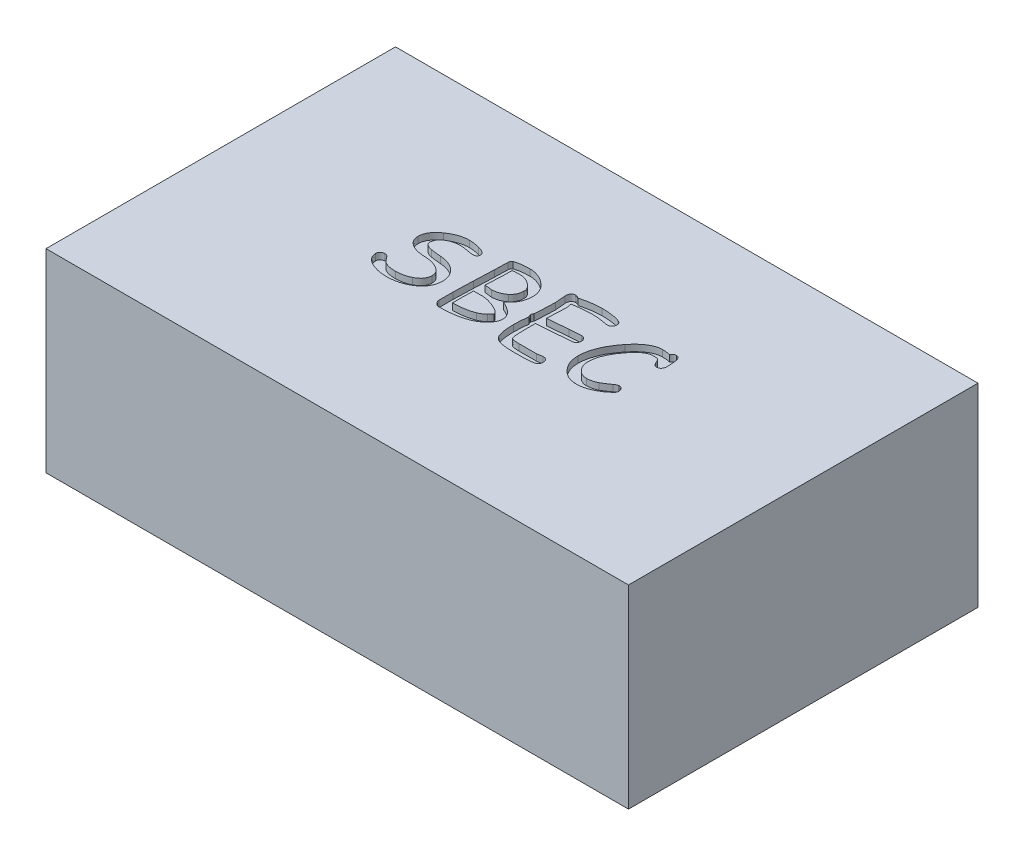
from build123d import *

# Parameters (mm, degrees)
SKICA1_W                 = 45
SKICA1_H                 = 27
P_IDAT_VYSUNUT_M1_DEPTH  = 15
ODEBRAT_VYSUNUT_M1_DEPTH = 0.5


with BuildPart() as part:
    # Skica1 → Přidat vysunutím1 (new body)
    with BuildSketch(Plane(origin=(0, 0, 0), x_dir=(1, 0, 0), z_dir=(0, 1, 0))):
        Rectangle(SKICA1_W, SKICA1_H)
    extrude(amount=P_IDAT_VYSUNUT_M1_DEPTH)

    # Skica2 → Odebrat vysunutím1 (cut)
    with BuildSketch(Plane(origin=(0, 15, 0), x_dir=(1, 0, 0), z_dir=(0, 1, 0))):
        with BuildLine():
            add(Edge.make_bspline(
                [(-9.448428748, -1.088679229), (-9.447731937, -1.06391265), (-9.446385447, -1.016054698), (-9.425496132, -0.947757461), (-9.390459162, -0.886735555), (-9.34168447, -0.834456243), (-9.283141779, -0.791103366), (-9.216734416, -0.760278758), (-9.143711397, -0.742089885), (-9.093271746, -0.739524158), (-9.067080901, -0.738191901)],
                knots=[0, 0, 0, 0, 7.405e-05, 0.000143092, 0.000211718, 0.000283486, 0.000356011, 0.000428987, 0.000501696, 0.000580229, 0.000580229, 0.000580229, 0.000580229], degree=3))
            add(Edge.make_bspline(
                [(-9.067080901, -0.738191901), (-9.036859517, -0.740334049), (-8.975703771, -0.744668883), (-8.889705252, -0.787561448), (-8.809282366, -0.851942649), (-8.766061049, -0.909328917), (-8.743045448, -0.939887439)],
                knots=[0, 0, 0, 0, 9.0095e-05, 0.000182315, 0.000282666, 0.000396972, 0.000396972, 0.000396972, 0.000396972], degree=3))
            add(Edge.make_bspline(
                [(-8.743045448, -0.939887439), (-8.712673736, -0.982146428), (-8.655801588, -1.061277942), (-8.569312316, -1.166111756), (-8.488016575, -1.250199945), (-8.430924359, -1.292825252), (-8.404681896, -1.312417995)],
                knots=[0, 0, 0, 0, 0.000156072, 0.00029225, 0.000407593, 0.00050571, 0.00050571, 0.00050571, 0.00050571], degree=3))
            add(Edge.make_bspline(
                [(-8.404681896, -1.312417995), (-8.377084825, -1.32884305), (-8.320479073, -1.362533315), (-8.226768677, -1.402320085), (-8.125508436, -1.438330834), (-8.014479987, -1.464946021), (-7.894924712, -1.487010104), (-7.766575626, -1.503764673), (-7.628869477, -1.511987479), (-7.53435067, -1.513388914), (-7.485479282, -1.514113532)],
                knots=[0, 0, 0, 0, 9.6242e-05, 0.000197407, 0.000304765, 0.000418373, 0.00053943, 0.000669438, 0.000806391, 0.000953015, 0.000953015, 0.000953015, 0.000953015], degree=3))
            add(Edge.make_bspline(
                [(-7.485479282, -1.514113532), (-7.437704911, -1.513071583), (-7.343136342, -1.511009062), (-7.202425049, -1.500442723), (-7.064657962, -1.479763414), (-6.928583334, -1.454057783), (-6.795399511, -1.418601042), (-6.665154838, -1.374928981), (-6.536630817, -1.326444796), (-6.454303946, -1.286253996), (-6.413076232, -1.266127215)],
                knots=[0, 0, 0, 0, 0.000143349, 0.000283757, 0.000422948, 0.00056107, 0.000699017, 0.000835991, 0.000973125, 0.001110688, 0.001110688, 0.001110688, 0.001110688], degree=3))
            add(Edge.make_bspline(
                [(-6.413076232, -1.266127215), (-6.3628633, -1.239249348), (-6.266607593, -1.187725804), (-6.136831815, -1.0963028), (-6.027361844, -0.997032605), (-5.93569017, -0.890727888), (-5.86731173, -0.774430137), (-5.816422368, -0.651537075), (-5.78598834, -0.520330313), (-5.782302907, -0.430110412), (-5.780435584, -0.384398089)],
                knots=[0, 0, 0, 0, 0.00017075, 0.000327319, 0.000474782, 0.000613221, 0.000746669, 0.000877659, 0.001011075, 0.001148103, 0.001148103, 0.001148103, 0.001148103], degree=3))
            add(Edge.make_bspline(
                [(-5.780435584, -0.384398089), (-5.782245433, -0.346432126), (-5.785797743, -0.271913825), (-5.810551573, -0.162970838), (-5.852951718, -0.060694045), (-5.912611703, 0.035246025), (-5.98828602, 0.125086371), (-6.080964155, 0.207954146), (-6.189990823, 0.284444514), (-6.270770486, 0.328061023), (-6.312779544, 0.350743569)],
                knots=[0, 0, 0, 0, 0.000113865, 0.000223489, 0.000333197, 0.000444538, 0.000561101, 0.000684396, 0.000816494, 0.000959627, 0.000959627, 0.000959627, 0.000959627], degree=3))
            add(Edge.make_bspline(
                [(-6.312779544, 0.350743569), (-6.351065057, 0.369768629), (-6.428538359, 0.408267112), (-6.551936437, 0.454624333), (-6.680817919, 0.496923204), (-6.816570452, 0.532257504), (-6.95948287, 0.559650705), (-7.108936132, 0.579807699), (-7.264723881, 0.596312509), (-7.370811523, 0.600104467), (-7.424860404, 0.60203637)],
                knots=[0, 0, 0, 0, 0.000128178, 0.000259377, 0.000394961, 0.000535039, 0.000679864, 0.000831213, 0.000987382, 0.001149583, 0.001149583, 0.001149583, 0.001149583], degree=3))
            add(Edge.make_bspline(
                [(-7.424860404, 0.60203637), (-7.47302536, 0.604472442), (-7.567715331, 0.609261642), (-7.706776265, 0.62493208), (-7.840345507, 0.646847291), (-7.968496831, 0.675293077), (-8.091110021, 0.711191191), (-8.209171811, 0.750972848), (-8.321030567, 0.799735208), (-8.391701509, 0.837780764), (-8.426725124, 0.856635655)],
                knots=[0, 0, 0, 0, 0.000144652, 0.000284379, 0.00041955, 0.000550573, 0.000677895, 0.000802678, 0.000924101, 0.0010434, 0.0010434, 0.0010434, 0.0010434], degree=3))
            add(Edge.make_bspline(
                [(-8.426725124, 0.856635655), (-8.468519121, 0.88176397), (-8.549985552, 0.930745027), (-8.658143547, 1.018152382), (-8.750336823, 1.113675149), (-8.824007562, 1.218340548), (-8.88442705, 1.329412656), (-8.924144889, 1.45008352), (-8.951224352, 1.578078998), (-8.953496426, 1.666575217), (-8.954660438, 1.711912908)],
                knots=[0, 0, 0, 0, 0.000146156, 0.000284893, 0.00041586, 0.000543087, 0.000667826, 0.000793651, 0.00092291, 0.001058695, 0.001058695, 0.001058695, 0.001058695], degree=3))
            add(Edge.make_bspline(
                [(-8.954660438, 1.711912908), (-8.95222202, 1.76610134), (-8.947327352, 1.874874504), (-8.910779597, 2.035353684), (-8.851207605, 2.192076105), (-8.767968108, 2.344976511), (-8.658821219, 2.492665214), (-8.530005256, 2.639103996), (-8.374752018, 2.779502376), (-8.259559664, 2.866066421), (-8.199679874, 2.911064519)],
                knots=[0, 0, 0, 0, 0.000162471, 0.00032613, 0.000491119, 0.000664229, 0.000846552, 0.001040961, 0.001248478, 0.00147313, 0.00147313, 0.00147313, 0.00147313], degree=3))
            add(Edge.make_bspline(
                [(-8.199679874, 2.911064519), (-8.140027214, 2.952054094), (-8.022585488, 3.032752698), (-7.838760173, 3.135769617), (-7.654464146, 3.224496731), (-7.468713394, 3.297981691), (-7.281024769, 3.354423543), (-7.091808138, 3.393748016), (-6.901308164, 3.419472655), (-6.77356509, 3.422201998), (-6.709557651, 3.423569573)],
                knots=[0, 0, 0, 0, 0.000217036, 0.000427292, 0.000631383, 0.000830322, 0.001025939, 0.00121854, 0.001409656, 0.001601588, 0.001601588, 0.001601588, 0.001601588], degree=3))
            add(Edge.make_bspline(
                [(-6.709557651, 3.423569573), (-6.647048131, 3.421882626), (-6.518001139, 3.418400029), (-6.318680187, 3.395426138), (-6.108306773, 3.356495459), (-5.965420114, 3.320757022), (-5.891753886, 3.302331819)],
                knots=[0, 0, 0, 0, 0.000187526, 0.000387136, 0.000601154, 0.000828918, 0.000828918, 0.000828918, 0.000828918], degree=3))
            add(Edge.make_bspline(
                [(-5.891753886, 3.302331819), (-5.844184578, 3.289319306), (-5.754912068, 3.264898945), (-5.631453531, 3.221739386), (-5.526426947, 3.176584472), (-5.440546236, 3.126978544), (-5.373010907, 3.075339389), (-5.3231877, 3.021093826), (-5.293265364, 2.961501189), (-5.288827795, 2.920167203), (-5.286667274, 2.900042905)],
                knots=[0, 0, 0, 0, 0.000147912, 0.000277583, 0.000392065, 0.000490361, 0.000574364, 0.000646217, 0.000709808, 0.000770146, 0.000770146, 0.000770146, 0.000770146], degree=3))
            add(Edge.make_bspline(
                [(-5.286667274, 2.900042905), (-5.287621106, 2.87458768), (-5.289410988, 2.82682051), (-5.305321713, 2.760062768), (-5.32992715, 2.70241576), (-5.367848182, 2.655435129), (-5.416665044, 2.619769749), (-5.475259887, 2.594040138), (-5.544328657, 2.58035604), (-5.593378128, 2.578238303), (-5.619520019, 2.577109612)],
                knots=[0, 0, 0, 0, 7.6249e-05, 0.000143082, 0.000204744, 0.000262751, 0.000321828, 0.000384496, 0.000453238, 0.000531685, 0.000531685, 0.000531685, 0.000531685], degree=3))
            add(Edge.make_bspline(
                [(-5.619520019, 2.577109612), (-5.648949904, 2.578116003), (-5.717252878, 2.580451707), (-5.833167778, 2.597271822), (-5.977139437, 2.618070669), (-6.13966856, 2.65025042), (-6.305600807, 2.681961459), (-6.459311834, 2.703826273), (-6.592467426, 2.717651037), (-6.674261833, 2.718018022), (-6.711761974, 2.718186273)],
                knots=[0, 0, 0, 0, 8.8283e-05, 0.000204894, 0.00035095, 0.000524749, 0.0007018, 0.000857669, 0.000990483, 0.001102925, 0.001102925, 0.001102925, 0.001102925], degree=3))
            add(Edge.make_bspline(
                [(-6.711761974, 2.718186273), (-6.759191167, 2.716560894), (-6.852411571, 2.713366268), (-6.988969811, 2.698792112), (-7.120163306, 2.676988569), (-7.245839292, 2.646182164), (-7.3664461, 2.606586538), (-7.481124133, 2.557669209), (-7.590912969, 2.501867718), (-7.659590164, 2.45791773), (-7.693787788, 2.436032952)],
                knots=[0, 0, 0, 0, 0.000142333, 0.00027975, 0.000411659, 0.00054104, 0.000667559, 0.00079202, 0.000914761, 0.001036499, 0.001036499, 0.001036499, 0.001036499], degree=3))
            add(Edge.make_bspline(
                [(-7.693787788, 2.436032952), (-7.726651023, 2.412836811), (-7.790348969, 2.36787634), (-7.874629051, 2.290928549), (-7.946231226, 2.210747381), (-8.0064118, 2.127184408), (-8.051346092, 2.038849667), (-8.083749023, 1.946953327), (-8.104600331, 1.851350534), (-8.106989977, 1.785865161), (-8.108200477, 1.75269288)],
                knots=[0, 0, 0, 0, 0.00012058, 0.000233716, 0.000341447, 0.000442666, 0.000541744, 0.000637607, 0.000734446, 0.000833861, 0.000833861, 0.000833861, 0.000833861], degree=3))
            add(Edge.make_bspline(
                [(-8.108200477, 1.75269288), (-8.106427551, 1.728235593), (-8.10289115, 1.679451401), (-8.076452339, 1.609354477), (-8.031539569, 1.546088513), (-7.969287937, 1.489803218), (-7.890881089, 1.439262472), (-7.796168873, 1.393968248), (-7.683722637, 1.356144486), (-7.60247103, 1.335837726), (-7.559324096, 1.325054254)],
                knots=[0, 0, 0, 0, 7.3275e-05, 0.00014616, 0.000221373, 0.000304043, 0.000396362, 0.000500374, 0.000618187, 0.00075159, 0.00075159, 0.00075159, 0.00075159], degree=3))
            add(Edge.make_bspline(
                [(-7.559324096, 1.325054254), (-7.540258674, 1.320810147), (-7.498666132, 1.311551333), (-7.42937957, 1.301091247), (-7.348534814, 1.290192329), (-7.255568089, 1.27920128), (-7.150850403, 1.268229217), (-7.03436526, 1.257418042), (-6.905837074, 1.245950849), (-6.816114358, 1.240000828), (-6.769074367, 1.236881341)],
                knots=[0, 0, 0, 0, 5.8581e-05, 0.000127798, 0.000210099, 0.000303334, 0.000408618, 0.000525966, 0.000654291, 0.000795716, 0.000795716, 0.000795716, 0.000795716], degree=3))
            add(Edge.make_bspline(
                [(-6.769074367, 1.236881341), (-6.700236492, 1.230598618), (-6.565561116, 1.218307011), (-6.370416962, 1.18235803), (-6.186308847, 1.135404833), (-6.013822498, 1.075046837), (-5.853271374, 1.000578121), (-5.703639802, 0.9148017), (-5.565805513, 0.815332282), (-5.48323426, 0.73918883), (-5.442072032, 0.701230897)],
                knots=[0, 0, 0, 0, 0.00020728, 0.000405525, 0.000594522, 0.000776832, 0.000952882, 0.001124724, 0.001293595, 0.001461461, 0.001461461, 0.001461461, 0.001461461], degree=3))
            add(Edge.make_bspline(
                [(-5.442072032, 0.701230897), (-5.407144584, 0.6651647), (-5.338096864, 0.593865799), (-5.248970248, 0.476501223), (-5.173284989, 0.353180694), (-5.111230907, 0.224024807), (-5.063814939, 0.088597736), (-5.029647847, -0.052398365), (-5.007894511, -0.199292473), (-5.00565118, -0.299455035), (-5.004513953, -0.350231086)],
                knots=[0, 0, 0, 0, 0.000150513, 0.000297547, 0.000441019, 0.000583981, 0.000726553, 0.000870637, 0.001018712, 0.001170954, 0.001170954, 0.001170954, 0.001170954], degree=3))
            add(Edge.make_bspline(
                [(-5.004513953, -0.350231086), (-5.007047559, -0.42205079), (-5.012035604, -0.563446112), (-5.051667927, -0.769531825), (-5.115582444, -0.964881051), (-5.207268688, -1.148142986), (-5.32417289, -1.320320117), (-5.466925781, -1.481138372), (-5.635374727, -1.630946091), (-5.762485937, -1.717570065), (-5.827828525, -1.762099849)],
                knots=[0, 0, 0, 0, 0.000215328, 0.000423928, 0.000627124, 0.0008302, 0.001036542, 0.001249716, 0.00147378, 0.001710809, 0.001710809, 0.001710809, 0.001710809], degree=3))
            add(Edge.make_bspline(
                [(-5.827828525, -1.762099849), (-5.887937776, -1.798638166), (-6.008299677, -1.871801969), (-6.198347438, -1.965429741), (-6.396121817, -2.043630373), (-6.600759952, -2.107228757), (-6.811829628, -2.158967763), (-7.030543701, -2.192874145), (-7.256078472, -2.216506705), (-7.408998898, -2.218490418), (-7.486581443, -2.219496833)],
                knots=[0, 0, 0, 0, 0.000210954, 0.000422411, 0.000634651, 0.000848336, 0.001064868, 0.001285928, 0.001511847, 0.001744497, 0.001744497, 0.001744497, 0.001744497], degree=3))
            add(Edge.make_bspline(
                [(-7.486581443, -2.219496833), (-7.54318345, -2.218607945), (-7.655046688, -2.216851225), (-7.821263321, -2.204098567), (-7.983666189, -2.185128459), (-8.142424653, -2.155672569), (-8.297392686, -2.119702796), (-8.4491109, -2.075547625), (-8.597010259, -2.022725737), (-8.692926751, -1.981221858), (-8.740841125, -1.960488902)],
                knots=[0, 0, 0, 0, 0.00016979, 0.000335558, 0.00049988, 0.000660073, 0.000819677, 0.000976978, 0.001133857, 0.001290449, 0.001290449, 0.001290449, 0.001290449], degree=3))
            add(Edge.make_bspline(
                [(-8.740841125, -1.960488902), (-8.795817431, -1.934044849), (-8.901441847, -1.883238642), (-9.044308429, -1.79213315), (-9.167227749, -1.694912842), (-9.266178921, -1.587304217), (-9.346639866, -1.474497083), (-9.403101922, -1.352235658), (-9.440167981, -1.223058877), (-9.445658165, -1.133748901), (-9.448428748, -1.088679229)],
                knots=[0, 0, 0, 0, 0.000182869, 0.000351341, 0.000507292, 0.000651574, 0.000788549, 0.000921184, 0.00105381, 0.001188923, 0.001188923, 0.001188923, 0.001188923], degree=3))
        make_face()
        with BuildLine():
            add(Edge.make_bspline(
                [(-1.32109053, -1.889950572), (-1.39206123, -1.91655142), (-1.537291749, -1.970985926), (-1.766066426, -2.037505259), (-2.009048896, -2.093380985), (-2.26654589, -2.139498567), (-2.538289515, -2.17581598), (-2.824804089, -2.200548767), (-3.125152643, -2.216268624), (-3.330310577, -2.218405855), (-3.435036109, -2.219496833)],
                knots=[0, 0, 0, 0, 0.000227313, 0.00046516, 0.000714065, 0.000975008, 0.001249661, 0.001536244, 0.001837529, 0.002151694, 0.002151694, 0.002151694, 0.002151694], degree=3))
            add(Edge.make_bspline(
                [(-3.435036109, -2.219496833), (-3.461368248, -2.217440334), (-3.51435698, -2.213301995), (-3.59225831, -2.183183452), (-3.667276919, -2.135090127), (-3.736806094, -2.069708327), (-3.796584361, -1.995408654), (-3.842383481, -1.917057611), (-3.870595486, -1.836364159), (-3.874151786, -1.78140973), (-3.875900672, -1.754384719)],
                knots=[0, 0, 0, 0, 7.888e-05, 0.000158731, 0.000247406, 0.000344902, 0.000443704, 0.000532563, 0.000616211, 0.00069715, 0.00069715, 0.00069715, 0.00069715], degree=3))
            Line((-3.875900672, -1.754384719), (-3.875900672, -0.664347087))
            add(Edge.make_bspline(
                [(-3.875900672, -0.664347087), (-3.875599657, -0.617320833), (-3.874967031, -0.518488592), (-3.872589169, -0.363083472), (-3.869524512, -0.193333746), (-3.864006982, -0.009261048), (-3.85556199, 0.188706915), (-3.848575025, 0.401113382), (-3.838460716, 0.627790639), (-3.830438054, 0.783897759), (-3.826303409, 0.864350785)],
                knots=[0, 0, 0, 0, 0.000141081, 0.000296501, 0.000466266, 0.00065041, 0.000848949, 0.001060704, 0.001287966, 0.001529644, 0.001529644, 0.001529644, 0.001529644], degree=3))
            add(Edge.make_bspline(
                [(-3.826303409, 0.864350785), (-3.821784918, 0.950681376), (-3.813095039, 1.116710762), (-3.802302307, 1.3566445), (-3.792434522, 1.578180236), (-3.783195542, 1.78131543), (-3.776991687, 1.966141599), (-3.770964472, 2.132176434), (-3.767905877, 2.279887218), (-3.766390748, 2.372107254), (-3.765684531, 2.415091886)],
                knots=[0, 0, 0, 0, 0.000259345, 0.000498768, 0.000720525, 0.000924615, 0.001108795, 0.001275312, 0.001423039, 0.001552011, 0.001552011, 0.001552011, 0.001552011], degree=3))
            add(Edge.make_bspline(
                [(-3.765684531, 2.415091886), (-3.765752931, 2.445585263), (-3.765897976, 2.510247894), (-3.764669527, 2.612386292), (-3.762433619, 2.725176395), (-3.759107447, 2.848253545), (-3.754644141, 2.981982719), (-3.749133818, 3.126000143), (-3.742492625, 3.280670485), (-3.737438453, 3.387200209), (-3.734824012, 3.442306317)],
                knots=[0, 0, 0, 0, 9.1479e-05, 0.000193986, 0.000306428, 0.000429915, 0.000563349, 0.000707837, 0.000862282, 0.001027786, 0.001027786, 0.001027786, 0.001027786], degree=3))
            add(Edge.make_bspline(
                [(-3.734824012, 3.442306317), (-3.729935791, 3.471230695), (-3.720908783, 3.524644935), (-3.694129681, 3.595482803), (-3.659840444, 3.652837722), (-3.626939518, 3.677519438), (-3.611381934, 3.689190473)],
                knots=[0, 0, 0, 0, 8.7759e-05, 0.000162063, 0.000226565, 0.000284426, 0.000284426, 0.000284426, 0.000284426], degree=3))
            add(Edge.make_bspline(
                [(-3.611381934, 3.689190473), (-3.523959986, 3.714002367), (-3.345360167, 3.764692154), (-3.063401237, 3.810541826), (-2.765263628, 3.841692109), (-2.560376755, 3.845067215), (-2.455214618, 3.846799554)],
                knots=[0, 0, 0, 0, 0.000272415, 0.000556533, 0.000855601, 0.001170975, 0.001170975, 0.001170975, 0.001170975], degree=3))
            add(Edge.make_bspline(
                [(-2.455214618, 3.846799554), (-2.400404871, 3.845624823), (-2.291115422, 3.843282435), (-2.128127304, 3.821308581), (-1.96689756, 3.786338363), (-1.807629905, 3.735829728), (-1.649537484, 3.673341514), (-1.493682391, 3.595194022), (-1.338836952, 3.504184245), (-1.240100321, 3.433189401), (-1.189933322, 3.3971177)],
                knots=[0, 0, 0, 0, 0.000164355, 0.000327721, 0.000492456, 0.000658736, 0.000828405, 0.001001907, 0.001181288, 0.00136657, 0.00136657, 0.00136657, 0.00136657], degree=3))
            add(Edge.make_bspline(
                [(-1.189933322, 3.3971177), (-1.13429892, 3.353719498), (-1.02619464, 3.269391616), (-0.882631223, 3.128312793), (-0.761904058, 2.979126539), (-0.662441722, 2.822088545), (-0.584442947, 2.657592726), (-0.530727951, 2.484596501), (-0.496062096, 2.304791382), (-0.492079299, 2.181962146), (-0.490060828, 2.119712628)],
                knots=[0, 0, 0, 0, 0.000211552, 0.00041107, 0.000602307, 0.000786081, 0.000967523, 0.001146691, 0.001328277, 0.001514868, 0.001514868, 0.001514868, 0.001514868], degree=3))
            add(Edge.make_bspline(
                [(-0.490060828, 2.119712628), (-0.492269777, 2.041310681), (-0.496588322, 1.888033086), (-0.53387348, 1.664904544), (-0.594467292, 1.454567188), (-0.680115289, 1.256859374), (-0.789446359, 1.071524747), (-0.925019637, 0.900692065), (-1.083231965, 0.741335351), (-1.20418132, 0.649143415), (-1.265982459, 0.60203637)],
                knots=[0, 0, 0, 0, 0.000235073, 0.000459574, 0.000676523, 0.000890277, 0.00110425, 0.001320107, 0.001543, 0.00177589, 0.00177589, 0.00177589, 0.00177589], degree=3))
            add(Edge.make_bspline(
                [(-1.265982459, 0.60203637), (-1.220268806, 0.582175559), (-1.1306964, 0.543259817), (-1.002465297, 0.48058109), (-0.882674872, 0.416745641), (-0.772572891, 0.35051052), (-0.670976632, 0.283349311), (-0.577831308, 0.215092697), (-0.493761196, 0.144521039), (-0.418792603, 0.071784794), (-0.352462571, -0.002195045), (-0.294214706, -0.077034513), (-0.246873774, -0.155170678), (-0.206907866, -0.234219279), (-0.17582703, -0.315082235), (-0.153565096, -0.39739978), (-0.139857832, -0.481662118), (-0.13820286, -0.538649722), (-0.137369178, -0.567356883)],
                knots=[0, 0, 0, 0, 0.000149509, 0.00029295, 0.000428063, 0.000556596, 0.000678259, 0.000793328, 0.000902836, 0.00100728, 0.001106408, 0.001200757, 0.001291302, 0.001380024, 0.001466197, 0.001550684, 0.001635486, 0.001721567, 0.001721567, 0.001721567, 0.001721567], degree=3))
            add(Edge.make_bspline(
                [(-0.137369178, -0.567356883), (-0.138984861, -0.604925527), (-0.142243129, -0.680688363), (-0.16480992, -0.793506902), (-0.203168286, -0.905107462), (-0.256443514, -1.015705936), (-0.32557444, -1.124910877), (-0.409179572, -1.233468581), (-0.506882827, -1.341506121), (-0.580940051, -1.408917992), (-0.619013713, -1.443575202)],
                knots=[0, 0, 0, 0, 0.000112685, 0.000227246, 0.000343659, 0.000465914, 0.000594659, 0.000730673, 0.000876579, 0.00103096, 0.00103096, 0.00103096, 0.00103096], degree=3))
            add(Edge.make_bspline(
                [(-0.619013713, -1.443575202), (-0.674388327, -1.491306267), (-0.7833771, -1.585250946), (-0.95846959, -1.70543489), (-1.135754982, -1.810415022), (-1.259839702, -1.863665176), (-1.32109053, -1.889950572)],
                knots=[0, 0, 0, 0, 0.000219156, 0.000431344, 0.000636269, 0.000836031, 0.000836031, 0.000836031, 0.000836031], degree=3))
        make_face()
        with BuildLine():
            add(Edge.make_bspline(
                [(-2.445295165, 3.070877923), (-2.509231039, 3.070974194), (-2.627212047, 3.071151844), (-2.788480454, 3.064914713), (-2.919511257, 3.058799155), (-2.996039788, 3.049560449), (-3.029440711, 3.045528211)],
                knots=[0, 0, 0, 0, 0.000191779, 0.000353891, 0.000484174, 0.000585075, 0.000585075, 0.000585075, 0.000585075], degree=3))
            Line((-3.029440711, 3.045528211), (-3.03605368, 2.416194047))
            Line((-3.03605368, 2.416194047), (-3.099979041, 1.025266351))
            add(Edge.make_bspline(
                [(-3.099979041, 1.025266351), (-3.057745098, 1.019271669), (-2.978469536, 1.008019304), (-2.867065048, 0.993966042), (-2.771540485, 0.981856787), (-2.691472473, 0.971809401), (-2.627173711, 0.963978827), (-2.578658351, 0.95900816), (-2.546037882, 0.954296541), (-2.529432519, 0.954615132), (-2.523548625, 0.954728021)],
                knots=[0, 0, 0, 0, 0.000127969, 0.000240206, 0.000336858, 0.000416831, 0.000482314, 0.000531122, 0.000563255, 0.000580889, 0.000580889, 0.000580889, 0.000580889], degree=3))
            add(Edge.make_bspline(
                [(-2.523548625, 0.954728021), (-2.476832498, 0.959383833), (-2.385275031, 0.968508614), (-2.251425476, 0.990220946), (-2.123893001, 1.021104973), (-2.003365292, 1.060986973), (-1.888531225, 1.106820817), (-1.781483773, 1.162881622), (-1.679580064, 1.224636598), (-1.617491521, 1.273350526), (-1.586711429, 1.297500218)],
                knots=[0, 0, 0, 0, 0.000140822, 0.000275993, 0.000406445, 0.00053401, 0.000656608, 0.000776885, 0.000896168, 0.001013438, 0.001013438, 0.001013438, 0.001013438], degree=3))
            add(Edge.make_bspline(
                [(-1.586711429, 1.297500218), (-1.555544252, 1.324730866), (-1.494155696, 1.378365823), (-1.414945851, 1.469604271), (-1.347027342, 1.565837725), (-1.291547627, 1.66793161), (-1.248149979, 1.775877779), (-1.217155375, 1.889743387), (-1.199673341, 2.009692304), (-1.196870592, 2.091369069), (-1.195444129, 2.132938565)],
                knots=[0, 0, 0, 0, 0.000124036, 0.000244308, 0.000361418, 0.000476824, 0.000592051, 0.000709694, 0.000830026, 0.000954746, 0.000954746, 0.000954746, 0.000954746], degree=3))
            add(Edge.make_bspline(
                [(-1.195444129, 2.132938565), (-1.19679783, 2.161697209), (-1.199516028, 2.21944384), (-1.219152214, 2.304749575), (-1.249978458, 2.388493357), (-1.295337082, 2.469351083), (-1.351972626, 2.549364874), (-1.421789238, 2.627362108), (-1.504198149, 2.703428709), (-1.596517987, 2.777281604), (-1.695993298, 2.845435714), (-1.79895173, 2.905162966), (-1.902797992, 2.956014112), (-2.007857728, 2.998621809), (-2.115384995, 3.030456973), (-2.224130904, 3.053285595), (-2.334273006, 3.068708529), (-2.408137145, 3.070151848), (-2.445295165, 3.070877923)],
                knots=[0, 0, 0, 0, 8.6223e-05, 0.000173133, 0.000261368, 0.000353112, 0.000450359, 0.000554977, 0.000666492, 0.000786465, 0.00090936, 0.001027887, 0.00114323, 0.001256002, 0.001367587, 0.001479129, 0.001589179, 0.001700585, 0.001700585, 0.001700585, 0.001700585], degree=3))
        make_face(mode=Mode.SUBTRACT)
        with BuildLine():
            Line((-2.022065185, 0.124800481), (-2.418843292, 0.189828004))
            add(Edge.make_bspline(
                [(-2.418843292, 0.189828004), (-2.439054205, 0.189594788), (-2.488327724, 0.189026215), (-2.566532859, 0.184318784), (-2.645838543, 0.179536453), (-2.696215484, 0.179023437), (-2.717529033, 0.17880639)],
                knots=[0, 0, 0, 0, 6.0629e-05, 0.000147811, 0.000234993, 0.000298928, 0.000298928, 0.000298928, 0.000298928], degree=3))
            add(Edge.make_bspline(
                [(-2.717529033, 0.17880639), (-2.787332589, 0.17880639), (-2.930980959, 0.17880639), (-3.074629329, 0.17880639), (-3.148474143, 0.17880639)],
                knots=[0, 0, 0, 0, 0.000209411, 0.000430945, 0.000430945, 0.000430945, 0.000430945], degree=3))
            add(Edge.make_bspline(
                [(-3.148474143, 0.17880639), (-3.152018921, 0.102031251), (-3.158903404, -0.047077408), (-3.165009133, -0.264609506), (-3.170121338, -0.469607826), (-3.170388079, -0.602255594), (-3.170517371, -0.66655141)],
                knots=[0, 0, 0, 0, 0.000230565, 0.000447792, 0.000652841, 0.000845723, 0.000845723, 0.000845723, 0.000845723], degree=3))
            Line((-3.170517371, -0.66655141), (-3.170517371, -1.443575202))
            add(Edge.make_bspline(
                [(-3.170517371, -1.443575202), (-3.090763131, -1.440060261), (-2.934771717, -1.433185383), (-2.706504091, -1.414242544), (-2.489202213, -1.389184998), (-2.283307373, -1.357289671), (-2.088817865, -1.319556484), (-1.906535015, -1.272047533), (-1.734202962, -1.222164226), (-1.625387156, -1.179835664), (-1.572383331, -1.159217559)],
                knots=[0, 0, 0, 0, 0.000239476, 0.000468392, 0.000686992, 0.00089556, 0.001093339, 0.001280995, 0.001460566, 0.001631102, 0.001631102, 0.001631102, 0.001631102], degree=3))
            add(Edge.make_bspline(
                [(-1.572383331, -1.159217559), (-1.528538854, -1.14073661), (-1.439582979, -1.103240688), (-1.313435708, -1.027542327), (-1.188286297, -0.940625757), (-1.110671722, -0.872365071), (-1.07089989, -0.837386428)],
                knots=[0, 0, 0, 0, 0.000142571, 0.000289262, 0.000440323, 0.000599084, 0.000599084, 0.000599084, 0.000599084], degree=3))
            add(Edge.make_bspline(
                [(-1.07089989, -0.837386428), (-1.036665415, -0.806866839), (-0.975740577, -0.75255314), (-0.90482032, -0.671333064), (-0.855132322, -0.603783149), (-0.846402522, -0.557889442), (-0.842752479, -0.538700686)],
                knots=[0, 0, 0, 0, 0.000137245, 0.000244245, 0.000324974, 0.000382982, 0.000382982, 0.000382982, 0.000382982], degree=3))
            add(Edge.make_bspline(
                [(-0.842752479, -0.538700686), (-0.844465696, -0.523045498), (-0.848087044, -0.489954017), (-0.872562509, -0.441295587), (-0.911177648, -0.392513636), (-0.965418791, -0.343472312), (-1.032887724, -0.291374878), (-1.116014764, -0.239220622), (-1.213633169, -0.185030382), (-1.284540562, -0.15039478), (-1.322192691, -0.132003127)],
                knots=[0, 0, 0, 0, 4.6929e-05, 9.9198e-05, 0.000160484, 0.000233001, 0.000317875, 0.000416017, 0.000527029, 0.000652719, 0.000652719, 0.000652719, 0.000652719], degree=3))
            add(Edge.make_bspline(
                [(-1.322192691, -0.132003127), (-1.381483093, -0.10466613), (-1.498274501, -0.05081717), (-1.67423936, 0.019645208), (-1.848147886, 0.079081369), (-1.964553219, 0.109681823), (-2.022065185, 0.124800481)],
                knots=[0, 0, 0, 0, 0.000195841, 0.000385771, 0.000568404, 0.000746754, 0.000746754, 0.000746754, 0.000746754], degree=3))
        make_face(mode=Mode.SUBTRACT)
        with BuildLine():
            add(Edge.make_bspline(
                [(4.290013196, 3.070877923), (4.271596915, 3.071553816), (4.232327221, 3.072995046), (4.193697601, 3.080250821), (4.173184087, 3.08410386)],
                knots=[0, 0, 0, 0, 5.5207e-05, 0.00011772, 0.00011772, 0.00011772, 0.00011772], degree=3))
            add(Edge.make_bspline(
                [(4.173184087, 3.08410386), (4.068293382, 3.103980174), (3.861116969, 3.143239167), (3.551178678, 3.181623586), (3.247085315, 3.207753315), (3.046094235, 3.210562357), (2.94647844, 3.211954583)],
                knots=[0, 0, 0, 0, 0.000320191, 0.000632429, 0.000936492, 0.001235277, 0.001235277, 0.001235277, 0.001235277], degree=3))
            add(Edge.make_bspline(
                [(2.94647844, 3.211954583), (2.893567986, 3.211518885), (2.785870823, 3.210632039), (2.62050334, 3.203556945), (2.44852086, 3.192645139), (2.269195622, 3.177117141), (2.083378029, 3.156734484), (1.889824282, 3.134603266), (1.689860064, 3.103797337), (1.554067168, 3.081975156), (1.485012414, 3.070877923)],
                knots=[0, 0, 0, 0, 0.000158727, 0.000323082, 0.000496472, 0.000675687, 0.000863006, 0.001057268, 0.001260057, 0.001469885, 0.001469885, 0.001469885, 0.001469885], degree=3))
            add(Edge.make_bspline(
                [(1.485012414, 3.070877923), (1.495716177, 3.030563215), (1.515851813, 2.954724249), (1.538022464, 2.846226326), (1.552412789, 2.750533005), (1.55456064, 2.690672382), (1.555550744, 2.663078202)],
                knots=[0, 0, 0, 0, 0.000125104, 0.000235342, 0.000332138, 0.000414917, 0.000414917, 0.000414917, 0.000414917], degree=3))
            add(Edge.make_bspline(
                [(1.555550744, 2.663078202), (1.55531882, 2.615683587), (1.554833347, 2.516475389), (1.551282572, 2.36106114), (1.545811683, 2.193155465), (1.537920311, 2.01240043), (1.528044849, 1.819146789), (1.515801283, 1.612677164), (1.501550884, 1.393704632), (1.490623952, 1.243487299), (1.485012414, 1.166343011)],
                knots=[0, 0, 0, 0, 0.000142183, 0.000297623, 0.000466344, 0.000646162, 0.000840396, 0.001046856, 0.001266654, 0.001498697, 0.001498697, 0.001498697, 0.001498697], degree=3))
            Line((1.485012414, 1.166343011), (3.106291844, 1.309623994))
            add(Edge.make_bspline(
                [(3.106291844, 1.309623994), (3.16321953, 1.315324293), (3.271514337, 1.326168099), (3.425584591, 1.338647046), (3.562194802, 1.351024287), (3.681162617, 1.361544417), (3.782666685, 1.367464539), (3.866743793, 1.373422785), (3.93361709, 1.377011723), (3.972588019, 1.377676107), (3.989123132, 1.377958001)],
                knots=[0, 0, 0, 0, 0.000171633, 0.000326501, 0.000463706, 0.000583152, 0.000684766, 0.000768712, 0.000836025, 0.000885634, 0.000885634, 0.000885634, 0.000885634], degree=3))
            add(Edge.make_bspline(
                [(3.989123132, 1.377958001), (4.01572473, 1.376824111), (4.0671594, 1.374631713), (4.140807433, 1.353616111), (4.207918217, 1.320677858), (4.266396001, 1.273363682), (4.316579924, 1.21681912), (4.35262277, 1.148526962), (4.373930634, 1.070993384), (4.376006498, 1.016221473), (4.377083947, 0.987792863)],
                knots=[0, 0, 0, 0, 7.9631e-05, 0.000153967, 0.000227903, 0.000302435, 0.000378228, 0.000453175, 0.000532055, 0.000617179, 0.000617179, 0.000617179, 0.000617179], degree=3))
            add(Edge.make_bspline(
                [(4.377083947, 0.987792863), (4.376150537, 0.960513287), (4.374377605, 0.908698104), (4.357796659, 0.835770223), (4.329943238, 0.772282173), (4.290445706, 0.718198742), (4.239721218, 0.672830121), (4.17682209, 0.639141445), (4.103708229, 0.614590655), (4.051026, 0.606366291), (4.023290135, 0.60203637)],
                knots=[0, 0, 0, 0, 8.1746e-05, 0.000155269, 0.000222861, 0.000288336, 0.000354695, 0.000425242, 0.000500874, 0.000584964, 0.000584964, 0.000584964, 0.000584964], degree=3))
            Line((4.023290135, 0.60203637), (3.136050202, 0.53149804))
            Line((3.136050202, 0.53149804), (1.414474084, 0.39042138))
            add(Edge.make_bspline(
                [(1.414474084, 0.39042138), (1.414474084, 0.306289726), (1.414474084, 0.142435063), (1.414474084, -0.095999188), (1.414474084, -0.319737954), (1.414474084, -0.463753711), (1.414474084, -0.533189879)],
                knots=[0, 0, 0, 0, 0.000252395, 0.000491564, 0.000715303, 0.000923611, 0.000923611, 0.000923611, 0.000923611], degree=3))
            add(Edge.make_bspline(
                [(1.414474084, -0.533189879), (1.414915128, -0.597120979), (1.415746701, -0.717660852), (1.421356952, -0.888166324), (1.42936178, -1.037858564), (1.442464963, -1.166912407), (1.458619027, -1.27557457), (1.477374039, -1.363565822), (1.500079807, -1.432102883), (1.522631885, -1.467019095), (1.532405354, -1.482150851)],
                knots=[0, 0, 0, 0, 0.000191789, 0.000361611, 0.000511764, 0.000641393, 0.000750663, 0.00084104, 0.000911475, 0.000965346, 0.000965346, 0.000965346, 0.000965346], degree=3))
            add(Edge.make_bspline(
                [(1.532405354, -1.482150851), (1.541615266, -1.490717361), (1.562072511, -1.509745468), (1.604663105, -1.529544674), (1.658239989, -1.547138287), (1.724500414, -1.560727641), (1.803266775, -1.571670957), (1.89456597, -1.578555299), (1.998169735, -1.58479331), (2.071350111, -1.584700697), (2.109937932, -1.584651862)],
                knots=[0, 0, 0, 0, 3.7538e-05, 8.3381e-05, 0.000139146, 0.00020681, 0.000285836, 0.00037764, 0.00048139, 0.000597122, 0.000597122, 0.000597122, 0.000597122], degree=3))
            add(Edge.make_bspline(
                [(2.109937932, -1.584651862), (2.152922227, -1.584651862), (2.248075495, -1.584651862), (2.405317189, -1.584651862), (2.590847693, -1.584651862), (2.795849714, -1.584651862), (3.001219123, -1.584651862), (3.188219175, -1.584651862), (3.346930418, -1.584651862), (3.443185848, -1.584651862), (3.48653753, -1.584651862)],
                knots=[0, 0, 0, 0, 0.000128953, 0.00028546, 0.000471725, 0.000685544, 0.000900466, 0.001087833, 0.001246545, 0.0013766, 0.0013766, 0.0013766, 0.0013766], degree=3))
            add(Edge.make_bspline(
                [(3.48653753, -1.584651862), (3.500149467, -1.584137966), (3.530438625, -1.58299445), (3.580083715, -1.575675654), (3.638542414, -1.564651905), (3.702561917, -1.549388082), (3.76657712, -1.53409344), (3.824688541, -1.52321258), (3.87357633, -1.515772343), (3.903135122, -1.514626836), (3.916380479, -1.514113532)],
                knots=[0, 0, 0, 0, 4.084e-05, 9.0876e-05, 0.000150321, 0.000219301, 0.000288281, 0.000347726, 0.00039667, 0.000436409, 0.000436409, 0.000436409, 0.000436409], degree=3))
            add(Edge.make_bspline(
                [(3.916380479, -1.514113532), (3.946948472, -1.515443731), (4.004609427, -1.51795291), (4.085784553, -1.534855644), (4.154636614, -1.566160836), (4.211735655, -1.60974986), (4.25471212, -1.667679756), (4.285604566, -1.736794183), (4.302824114, -1.818601755), (4.30525155, -1.876643237), (4.306545617, -1.907585155)],
                knots=[0, 0, 0, 0, 9.1718e-05, 0.00017301, 0.000246986, 0.000316875, 0.000386093, 0.000461072, 0.000542363, 0.000635181, 0.000635181, 0.000635181, 0.000635181], degree=3))
            add(Edge.make_bspline(
                [(4.306545617, -1.907585155), (4.305980072, -1.932674122), (4.304886814, -1.981173794), (4.288687169, -2.049425013), (4.265292241, -2.110945552), (4.228251017, -2.162294088), (4.183800298, -2.207397838), (4.12852478, -2.24441545), (4.062750571, -2.271535082), (4.015031815, -2.282982223), (3.990225293, -2.288933002)],
                knots=[0, 0, 0, 0, 7.5077e-05, 0.000145131, 0.000209398, 0.000271158, 0.000333506, 0.000398617, 0.000469241, 0.000545705, 0.000545705, 0.000545705, 0.000545705], degree=3))
            add(Edge.make_bspline(
                [(3.990225293, -2.288933002), (3.95684455, -2.294805251), (3.881935547, -2.307983039), (3.755956588, -2.3208282), (3.605045748, -2.334747017), (3.428550774, -2.343699573), (3.226478479, -2.351483032), (2.999036731, -2.356704039), (2.745895362, -2.360032773), (2.56880575, -2.360387372), (2.475855519, -2.360573493)],
                knots=[0, 0, 0, 0, 0.00010165, 0.000228111, 0.000379685, 0.00055631, 0.000758153, 0.000986367, 0.001238783, 0.001517632, 0.001517632, 0.001517632, 0.001517632], degree=3))
            add(Edge.make_bspline(
                [(2.475855519, -2.360573493), (2.383989604, -2.359891301), (2.20895027, -2.358591467), (1.959186296, -2.344483659), (1.735147915, -2.320510963), (1.536456272, -2.288577101), (1.363108923, -2.246375378), (1.216127477, -2.193776932), (1.092250656, -2.133971321), (1.026448162, -2.08036324), (0.995652749, -2.055274783)],
                knots=[0, 0, 0, 0, 0.000275576, 0.000525076, 0.000750125, 0.00095125, 0.001128479, 0.001284321, 0.001419384, 0.001538198, 0.001538198, 0.001538198, 0.001538198], degree=3))
            add(Edge.make_bspline(
                [(0.995652749, -2.055274783), (0.96642745, -2.024315594), (0.904313731, -1.958516766), (0.83331314, -1.831678883), (0.773344236, -1.679797805), (0.722975977, -1.501824709), (0.686049911, -1.296873957), (0.657196792, -1.065868153), (0.641452158, -0.807478688), (0.639550575, -0.626158654), (0.638552453, -0.530985557)],
                knots=[0, 0, 0, 0, 0.000127322, 0.000270603, 0.000432291, 0.000616839, 0.000824356, 0.001056484, 0.001314919, 0.001600432, 0.001600432, 0.001600432, 0.001600432], degree=3))
            add(Edge.make_bspline(
                [(0.638552453, -0.530985557), (0.639399362, -0.447937596), (0.641169271, -0.274380336), (0.656726053, -0.002800471), (0.680486215, 0.291011318), (0.699326068, 0.4944102), (0.709090783, 0.599832047)],
                knots=[0, 0, 0, 0, 0.000249127, 0.000520638, 0.000815823, 0.001133439, 0.001133439, 0.001133439, 0.001133439], degree=3))
            add(Edge.make_bspline(
                [(0.709090783, 0.599832047), (0.698343205, 0.614230216), (0.677751607, 0.641816088), (0.65498802, 0.687085745), (0.641138023, 0.733844281), (0.639411029, 0.76580125), (0.638552453, 0.78168868)],
                knots=[0, 0, 0, 0, 5.3814e-05, 0.000103105, 0.000151248, 0.000198845, 0.000198845, 0.000198845, 0.000198845], degree=3))
            add(Edge.make_bspline(
                [(0.638552453, 0.78168868), (0.639356669, 0.802342103), (0.640939302, 0.842986348), (0.654790898, 0.902063165), (0.676607932, 0.958147485), (0.698206353, 0.991783306), (0.709090783, 1.00873393)],
                knots=[0, 0, 0, 0, 6.1878e-05, 0.000121771, 0.000181125, 0.000241422, 0.000241422, 0.000241422, 0.000241422], degree=3))
            add(Edge.make_bspline(
                [(0.709090783, 1.00873393), (0.714682687, 1.095432231), (0.725485961, 1.262928922), (0.739806053, 1.505407983), (0.751991943, 1.730248954), (0.761962291, 1.937457144), (0.769759675, 2.127031883), (0.775324219, 2.299341147), (0.778868553, 2.454019973), (0.779386689, 2.551390948), (0.779629113, 2.596948518)],
                knots=[0, 0, 0, 0, 0.000260635, 0.000503533, 0.000728701, 0.000936145, 0.001125873, 0.001297899, 0.001453339, 0.001590011, 0.001590011, 0.001590011, 0.001590011], degree=3))
            add(Edge.make_bspline(
                [(0.779629113, 2.596948518), (0.779124861, 2.622676027), (0.778014212, 2.679342579), (0.770667725, 2.772316181), (0.759750459, 2.881100053), (0.744263795, 3.000695147), (0.729062738, 3.120325419), (0.718038985, 3.229463713), (0.710740787, 3.322072792), (0.70960321, 3.378370926), (0.709090783, 3.403730668)],
                knots=[0, 0, 0, 0, 7.7183e-05, 0.00017, 0.000279669, 0.000405166, 0.000531756, 0.000641425, 0.000734243, 0.000810324, 0.000810324, 0.000810324, 0.000810324], degree=3))
            add(Edge.make_bspline(
                [(0.709090783, 3.403730668), (0.709947181, 3.438336166), (0.711563663, 3.503655315), (0.728705052, 3.595136425), (0.758776716, 3.672726277), (0.799122566, 3.737989979), (0.854824323, 3.786439581), (0.92018305, 3.822884467), (0.998459504, 3.843826757), (1.05430861, 3.84577165), (1.083825661, 3.846799554)],
                knots=[0, 0, 0, 0, 0.00010375, 0.000195831, 0.000277495, 0.000352394, 0.000423421, 0.000496431, 0.00057531, 0.000663731, 0.000663731, 0.000663731, 0.000663731], degree=3))
            add(Edge.make_bspline(
                [(1.083825661, 3.846799554), (1.109303853, 3.845570006), (1.159238578, 3.843160213), (1.231167735, 3.822907871), (1.296925638, 3.787695421), (1.334574772, 3.755351385), (1.353855206, 3.738787736)],
                knots=[0, 0, 0, 0, 7.6336e-05, 0.000149611, 0.000222095, 0.000298176, 0.000298176, 0.000298176, 0.000298176], degree=3))
            add(Edge.make_bspline(
                [(1.353855206, 3.738787736), (1.427595948, 3.758660836), (1.572755791, 3.797781355), (1.788083894, 3.848464638), (1.997405872, 3.890128688), (2.1997881, 3.925808899), (2.396808121, 3.953503664), (2.587563839, 3.973652995), (2.77294226, 3.984672517), (2.894296892, 3.986817514), (2.95419357, 3.987876214)],
                knots=[0, 0, 0, 0, 0.000229106, 0.000451, 0.000663477, 0.000869319, 0.001067429, 0.001260228, 0.001444619, 0.001624325, 0.001624325, 0.001624325, 0.001624325], degree=3))
            add(Edge.make_bspline(
                [(2.95419357, 3.987876214), (3.02805177, 3.987301947), (3.17216368, 3.986181439), (3.382752299, 3.975722356), (3.582046775, 3.960839944), (3.769747682, 3.939426182), (3.94571801, 3.909059149), (4.110476012, 3.874039419), (4.264633206, 3.834649953), (4.361152264, 3.799779367), (4.407944466, 3.782874192)],
                knots=[0, 0, 0, 0, 0.000221559, 0.000432306, 0.000632393, 0.000821052, 0.000998805, 0.001167849, 0.001326384, 0.001475563, 0.001475563, 0.001475563, 0.001475563], degree=3))
            add(Edge.make_bspline(
                [(4.407944466, 3.782874192), (4.427622792, 3.77448763), (4.465804971, 3.758215045), (4.517670441, 3.727631676), (4.561925029, 3.691896017), (4.597037231, 3.650765218), (4.625625813, 3.605768762), (4.645792688, 3.555424837), (4.656194696, 3.500039619), (4.658209146, 3.46181509), (4.659237267, 3.442306317)],
                knots=[0, 0, 0, 0, 6.4125e-05, 0.000124422, 0.000180024, 0.00023394, 0.000285929, 0.000339346, 0.000395546, 0.000454127, 0.000454127, 0.000454127, 0.000454127], degree=3))
            add(Edge.make_bspline(
                [(4.659237267, 3.442306317), (4.657799206, 3.419426413), (4.654949832, 3.374092188), (4.63713778, 3.307888713), (4.605452004, 3.245943326), (4.576166836, 3.209636987), (4.561144902, 3.191013516)],
                knots=[0, 0, 0, 0, 6.8653e-05, 0.000136029, 0.000204052, 0.000275692, 0.000275692, 0.000275692, 0.000275692], degree=3))
            add(Edge.make_bspline(
                [(4.561144902, 3.191013516), (4.542825498, 3.172399721), (4.506878308, 3.135874863), (4.440131875, 3.09848625), (4.367248056, 3.075072512), (4.31628498, 3.072304731), (4.290013196, 3.070877923)],
                knots=[0, 0, 0, 0, 7.7997e-05, 0.000153049, 0.000226952, 0.000305584, 0.000305584, 0.000305584, 0.000305584], degree=3))
        make_face()
        with BuildLine():
            add(Edge.make_bspline(
                [(9.027102925, 2.153879632), (9.008283444, 2.154671097), (8.971618955, 2.156213045), (8.918097502, 2.170091538), (8.868508799, 2.193352514), (8.822561443, 2.22581154), (8.781582884, 2.268011986), (8.742775632, 2.317456987), (8.708385763, 2.376981179), (8.689728502, 2.420745284), (8.679922082, 2.443748082)],
                knots=[0, 0, 0, 0, 5.6383e-05, 0.000109846, 0.000164578, 0.000219928, 0.0002776, 0.000340433, 0.000408106, 0.000483085, 0.000483085, 0.000483085, 0.000483085], degree=3))
            add(Edge.make_bspline(
                [(8.679922082, 2.443748082), (8.66322388, 2.481519484), (8.633080782, 2.549703301), (8.584553526, 2.638413441), (8.538406162, 2.704642142), (8.501600443, 2.733473979), (8.485941674, 2.745740308)],
                knots=[0, 0, 0, 0, 0.000123781, 0.000223446, 0.000303685, 0.000363099, 0.000363099, 0.000363099, 0.000363099], degree=3))
            add(Edge.make_bspline(
                [(8.485941674, 2.745740308), (8.468107844, 2.752621904), (8.424496762, 2.769450252), (8.340255536, 2.779239129), (8.229027599, 2.788706779), (8.144691243, 2.78871825), (8.097980859, 2.788724603)],
                knots=[0, 0, 0, 0, 5.7164e-05, 0.000139789, 0.000252555, 0.000392547, 0.000392547, 0.000392547, 0.000392547], degree=3))
            add(Edge.make_bspline(
                [(8.097980859, 2.788724603), (8.051807372, 2.785970983), (7.956840839, 2.780307522), (7.814130292, 2.738849019), (7.668574521, 2.673609035), (7.519192746, 2.583179196), (7.366824293, 2.466190184), (7.212300678, 2.322522063), (7.051343785, 2.156108527), (6.94900681, 2.031589286), (6.895522763, 1.966512193)],
                knots=[0, 0, 0, 0, 0.000138404, 0.000284659, 0.000442561, 0.00061608, 0.0008072, 0.001017831, 0.001248565, 0.001501171, 0.001501171, 0.001501171, 0.001501171], degree=3))
            add(Edge.make_bspline(
                [(6.895522763, 1.966512193), (6.824175559, 1.875910732), (6.685672908, 1.700030785), (6.503111111, 1.429106673), (6.349292406, 1.161447624), (6.221179855, 0.898019693), (6.122233275, 0.637269662), (6.052426382, 0.380008974), (6.00822992, 0.126323744), (6.002362438, -0.042190919), (5.999465539, -0.125390159)],
                knots=[0, 0, 0, 0, 0.000345879, 0.000671436, 0.000979026, 0.00127135, 0.001549342, 0.001814304, 0.00207015, 0.00231965, 0.00231965, 0.00231965, 0.00231965], degree=3))
            add(Edge.make_bspline(
                [(5.999465539, -0.125390159), (6.000215908, -0.164377761), (6.001700672, -0.241522939), (6.016431807, -0.355166387), (6.04049954, -0.464814998), (6.074966476, -0.569837514), (6.118432942, -0.670714318), (6.169916451, -0.768473155), (6.23309158, -0.861059949), (6.281484811, -0.918608377), (6.30586641, -0.947602569)],
                knots=[0, 0, 0, 0, 0.000116912, 0.000231336, 0.000343111, 0.00045325, 0.00056237, 0.000672327, 0.000784211, 0.000897819, 0.000897819, 0.000897819, 0.000897819], degree=3))
            add(Edge.make_bspline(
                [(6.30586641, -0.947602569), (6.33218738, -0.975662897), (6.3840129, -1.030913184), (6.468779088, -1.103529227), (6.557730881, -1.165058024), (6.651167032, -1.214661585), (6.747948681, -1.254990877), (6.849497035, -1.282337461), (6.954456414, -1.299418628), (7.025879233, -1.301465056), (7.061949136, -1.302498542)],
                knots=[0, 0, 0, 0, 0.000115354, 0.000227129, 0.00033413, 0.00043916, 0.000543952, 0.000647965, 0.000753967, 0.000862119, 0.000862119, 0.000862119, 0.000862119], degree=3))
            add(Edge.make_bspline(
                [(7.061949136, -1.302498542), (7.125695912, -1.300187153), (7.254208064, -1.295527442), (7.446214761, -1.256351548), (7.639730534, -1.198215285), (7.763579667, -1.139576478), (7.826849152, -1.109620296)],
                knots=[0, 0, 0, 0, 0.000191059, 0.000385171, 0.00058597, 0.000795685, 0.000795685, 0.000795685, 0.000795685], degree=3))
            add(Edge.make_bspline(
                [(7.826849152, -1.109620296), (7.846048716, -1.099502885), (7.887104364, -1.077868183), (7.950707677, -1.039528591), (8.022902611, -0.99729163), (8.100772927, -0.945723371), (8.18676443, -0.888988023), (8.278982384, -0.824353301), (8.379912147, -0.755603497), (8.4482447, -0.70569852), (8.483737351, -0.679777347)],
                knots=[0, 0, 0, 0, 6.5093e-05, 0.000139192, 0.000222739, 0.00031598, 0.000419302, 0.000531809, 0.000653796, 0.000785636, 0.000785636, 0.000785636, 0.000785636], degree=3))
            add(Edge.make_bspline(
                [(8.483737351, -0.679777347), (8.516373708, -0.65665272), (8.575745872, -0.614584325), (8.662191387, -0.567059916), (8.735069867, -0.534708454), (8.781106851, -0.52904418), (8.801159837, -0.526576911)],
                knots=[0, 0, 0, 0, 0.000119832, 0.000217999, 0.000296182, 0.00035652, 0.00035652, 0.00035652, 0.00035652], degree=3))
            add(Edge.make_bspline(
                [(8.801159837, -0.526576911), (8.826670949, -0.528067944), (8.876495584, -0.530980014), (8.948467736, -0.553899658), (9.012934442, -0.593265952), (9.068412237, -0.646409914), (9.113914651, -0.707509297), (9.149509364, -0.773112723), (9.169867533, -0.843911022), (9.172411273, -0.892372968), (9.173690392, -0.916742049)],
                knots=[0, 0, 0, 0, 7.6439e-05, 0.000149291, 0.000223953, 0.000301144, 0.000378295, 0.000451753, 0.000523967, 0.00059701, 0.00059701, 0.00059701, 0.00059701], degree=3))
            add(Edge.make_bspline(
                [(9.173690392, -0.916742049), (9.172027379, -0.943790059), (9.16871001, -0.997745282), (9.140601976, -1.075360391), (9.095441081, -1.147869283), (9.054133129, -1.188664628), (9.032613732, -1.209916984)],
                knots=[0, 0, 0, 0, 8.0939e-05, 0.000161458, 0.00024464, 0.000335098, 0.000335098, 0.000335098, 0.000335098], degree=3))
            add(Edge.make_bspline(
                [(9.032613732, -1.209916984), (8.951288256, -1.279095683), (8.792904617, -1.413823136), (8.544925513, -1.590844117), (8.296373725, -1.740176246), (8.04773572, -1.864031232), (7.797341632, -1.95936139), (7.546498233, -2.02811582), (7.294509983, -2.070968544), (7.126037619, -2.075942374), (7.04211023, -2.078420173)],
                knots=[0, 0, 0, 0, 0.000320198, 0.000623595, 0.000912794, 0.001189316, 0.00145583, 0.001715184, 0.001968677, 0.002220317, 0.002220317, 0.002220317, 0.002220317], degree=3))
            add(Edge.make_bspline(
                [(7.04211023, -2.078420173), (6.978797331, -2.077006911), (6.854428392, -2.074230766), (6.672045425, -2.043912024), (6.497053655, -1.997632613), (6.328412795, -1.934339784), (6.168953753, -1.848823741), (6.016055353, -1.747206603), (5.870494061, -1.626641852), (5.782869021, -1.533820845), (5.738253285, -1.486559497)],
                knots=[0, 0, 0, 0, 0.000189777, 0.000372789, 0.000552978, 0.000732288, 0.000911748, 0.001094547, 0.001282374, 0.001477217, 0.001477217, 0.001477217, 0.001477217], degree=3))
            add(Edge.make_bspline(
                [(5.738253285, -1.486559497), (5.697278904, -1.438417737), (5.616187137, -1.343141119), (5.511766157, -1.188763915), (5.421351977, -1.029043068), (5.349893068, -0.861217839), (5.293562665, -0.687828698), (5.252398484, -0.507941873), (5.227667616, -0.321535786), (5.224928321, -0.194900994), (5.223543908, -0.130900966)],
                knots=[0, 0, 0, 0, 0.000189527, 0.00037509, 0.000558148, 0.000739339, 0.000921279, 0.001104427, 0.001292264, 0.001484195, 0.001484195, 0.001484195, 0.001484195], degree=3))
            add(Edge.make_bspline(
                [(5.223543908, -0.130900966), (5.226825806, -0.025282112), (5.233459021, 0.188189638), (5.28498603, 0.50886867), (5.369766255, 0.830574903), (5.486355335, 1.154552745), (5.637377562, 1.479423968), (5.820354405, 1.806947993), (6.036777846, 2.136155402), (6.20152529, 2.348936537), (6.286027505, 2.45807618)],
                knots=[0, 0, 0, 0, 0.000316752, 0.000640204, 0.000971691, 0.001313697, 0.001671723, 0.002045225, 0.002438343, 0.002852316, 0.002852316, 0.002852316, 0.002852316], degree=3))
            add(Edge.make_bspline(
                [(6.286027505, 2.45807618), (6.358554364, 2.545585657), (6.498414102, 2.714337657), (6.721911097, 2.939421721), (6.944180774, 3.13192814), (7.168052942, 3.289087189), (7.392414016, 3.41221791), (7.618450535, 3.49917089), (7.845185279, 3.553958852), (7.997394062, 3.561110942), (8.072631146, 3.564646234)],
                knots=[0, 0, 0, 0, 0.000340826, 0.000657245, 0.000950372, 0.001221882, 0.001476357, 0.001716044, 0.001946775, 0.002172306, 0.002172306, 0.002172306, 0.002172306], degree=3))
            add(Edge.make_bspline(
                [(8.072631146, 3.564646234), (8.130704716, 3.563799491), (8.240377939, 3.562200399), (8.396162602, 3.550433197), (8.534888898, 3.529909528), (8.619863925, 3.505609344), (8.660083176, 3.494107903)],
                knots=[0, 0, 0, 0, 0.000174197, 0.000328975, 0.000468498, 0.000593878, 0.000593878, 0.000593878, 0.000593878], degree=3))
            add(Edge.make_bspline(
                [(8.660083176, 3.494107903), (8.682140286, 3.526241057), (8.723934054, 3.587126894), (8.806865921, 3.655204874), (8.900106995, 3.698791078), (8.96674878, 3.703385567), (9.000651051, 3.705722894)],
                knots=[0, 0, 0, 0, 0.000116392, 0.000220539, 0.000318234, 0.000419399, 0.000419399, 0.000419399, 0.000419399], degree=3))
            add(Edge.make_bspline(
                [(9.000651051, 3.705722894), (9.021351019, 3.704773866), (9.061270424, 3.70294369), (9.118064958, 3.685634691), (9.16874574, 3.657459798), (9.213612942, 3.618137715), (9.251181447, 3.567004503), (9.283256327, 3.505771507), (9.308295739, 3.433185805), (9.319743988, 3.38072864), (9.325788666, 3.353031243)],
                knots=[0, 0, 0, 0, 6.1967e-05, 0.000119501, 0.000176238, 0.000234819, 0.000296981, 0.000365511, 0.000441504, 0.000526513, 0.000526513, 0.000526513, 0.000526513], degree=3))
            add(Edge.make_bspline(
                [(9.325788666, 3.353031243), (9.335268246, 3.298015714), (9.355160983, 3.182566559), (9.372710896, 2.998817131), (9.383896271, 2.797319414), (9.384822953, 2.65685051), (9.385305382, 2.583722581)],
                knots=[0, 0, 0, 0, 0.000167427, 0.000351343, 0.000553339, 0.000772694, 0.000772694, 0.000772694, 0.000772694], degree=3))
            add(Edge.make_bspline(
                [(9.385305382, 2.583722581), (9.384747684, 2.557896146), (9.383661109, 2.50757802), (9.366745484, 2.435210135), (9.343561368, 2.366367234), (9.318520439, 2.325427637), (9.305949761, 2.304875745)],
                knots=[0, 0, 0, 0, 7.7277e-05, 0.000150561, 0.000222031, 0.000294078, 0.000294078, 0.000294078, 0.000294078], degree=3))
            add(Edge.make_bspline(
                [(9.305949761, 2.304875745), (9.289078176, 2.281773592), (9.256306205, 2.236899143), (9.188799543, 2.188175726), (9.110841728, 2.159515336), (9.05563844, 2.1558001), (9.027102925, 2.153879632)],
                knots=[0, 0, 0, 0, 8.538e-05, 0.000165846, 0.000245697, 0.000331141, 0.000331141, 0.000331141, 0.000331141], degree=3))
        make_face()
    extrude(amount=-ODEBRAT_VYSUNUT_M1_DEPTH, mode=Mode.SUBTRACT)


solid = part.part
